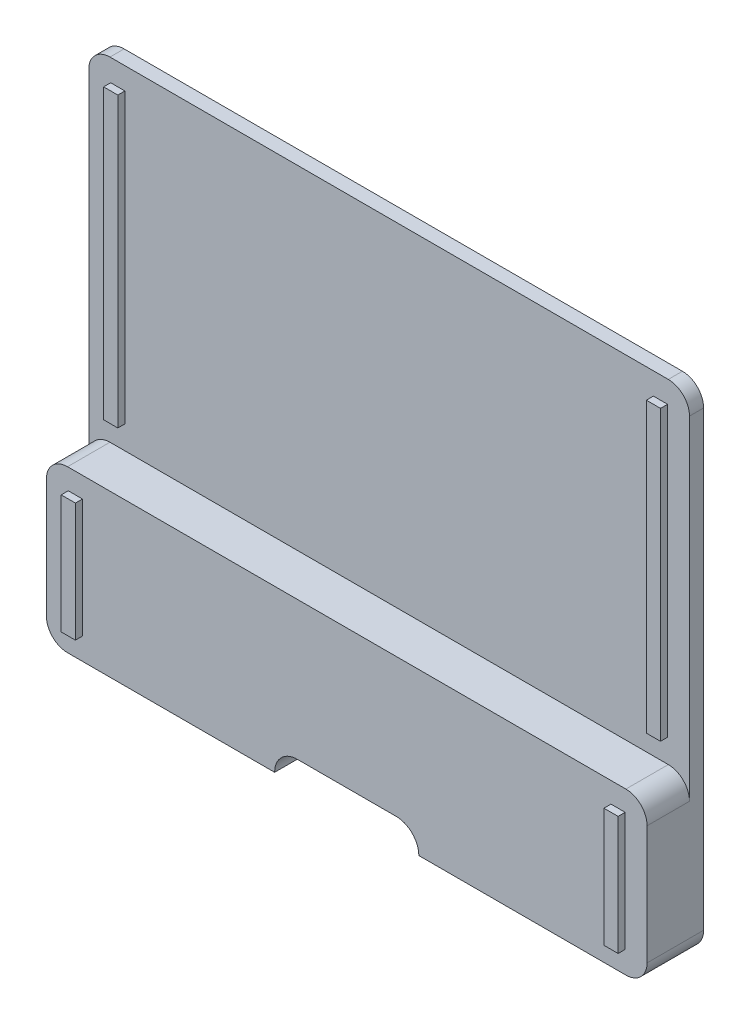
from build123d import *

# Parameters (mm, degrees)
BOSS_EXTRUDE1_DEPTH = 8
CUT_EXTRUDE1_DEPTH  = 6
SKETCH3_W           = 2.01
SKETCH3_H           = 16.8
BOSS_EXTRUDE2_DEPTH = 1
SKETCH4_W           = 2.01
SKETCH4_H           = 40.8
BOSS_EXTRUDE3_DEPTH = 1


with BuildPart() as part:
    # Sketch1 → Boss-Extrude1 (new body)
    with BuildSketch(Plane.XY):
        with BuildLine():
            Line((3, 70), (82, 70))
            ThreePointArc((82, 70), (84.121320344, 69.121320344), (85, 67))
            Line((85, 67), (85, 3))
            ThreePointArc((85, 3), (84.121320344, 0.878679656), (82, 0))
            Line((82, 0), (52.7, 0))
            ThreePointArc((52.7, 0), (51.7627417, 2.2627417), (49.5, 3.2))
            Line((49.5, 3.2), (35.5, 3.2))
            ThreePointArc((35.5, 3.2), (33.2372583, 2.2627417), (32.3, 0))
            Line((32.3, 0), (3, 0))
            ThreePointArc((3, 0), (0.878679656, 0.878679656), (0, 3))
            Line((0, 3), (0, 67))
            ThreePointArc((0, 67), (0.878679656, 69.121320344), (3, 70))
        make_face()
    extrude(amount=BOSS_EXTRUDE1_DEPTH)

    # Sketch2 → Cut-Extrude1 (cut)
    with BuildSketch(Plane.XY.offset(8)):
        with BuildLine():
            Line((3, 70), (82, 70))
            ThreePointArc((82, 70), (84.121320344, 69.121320344), (85, 67))
            Line((85, 67), (85, 19.8))
            ThreePointArc((85, 19.8), (84.121320344, 21.921320344), (82, 22.8))
            Line((82, 22.8), (3, 22.8))
            ThreePointArc((3, 22.8), (0.878679656, 21.921320344), (0, 19.8))
            Line((0, 19.8), (0, 67))
            ThreePointArc((0, 67), (0.878679656, 69.121320344), (3, 70))
        make_face()
    extrude(amount=-CUT_EXTRUDE1_DEPTH, mode=Mode.SUBTRACT)

    # Sketch3 → Boss-Extrude2 (add)
    with BuildSketch(Plane.XY.offset(8)):
        with Locations((4.105, 11.5)):
            Rectangle(SKETCH3_W, SKETCH3_H)
        with Locations((80.895, 11.5)):
            Rectangle(SKETCH3_W, SKETCH3_H)
    extrude(amount=BOSS_EXTRUDE2_DEPTH)

    # Sketch4 → Boss-Extrude3 (add)
    with BuildSketch(Plane.XY.offset(2)):
        with Locations((4.105, 46.5)):
            Rectangle(SKETCH4_W, SKETCH4_H)
        with Locations((80.895, 46.5)):
            Rectangle(SKETCH4_W, SKETCH4_H)
    extrude(amount=BOSS_EXTRUDE3_DEPTH)


solid = part.part
